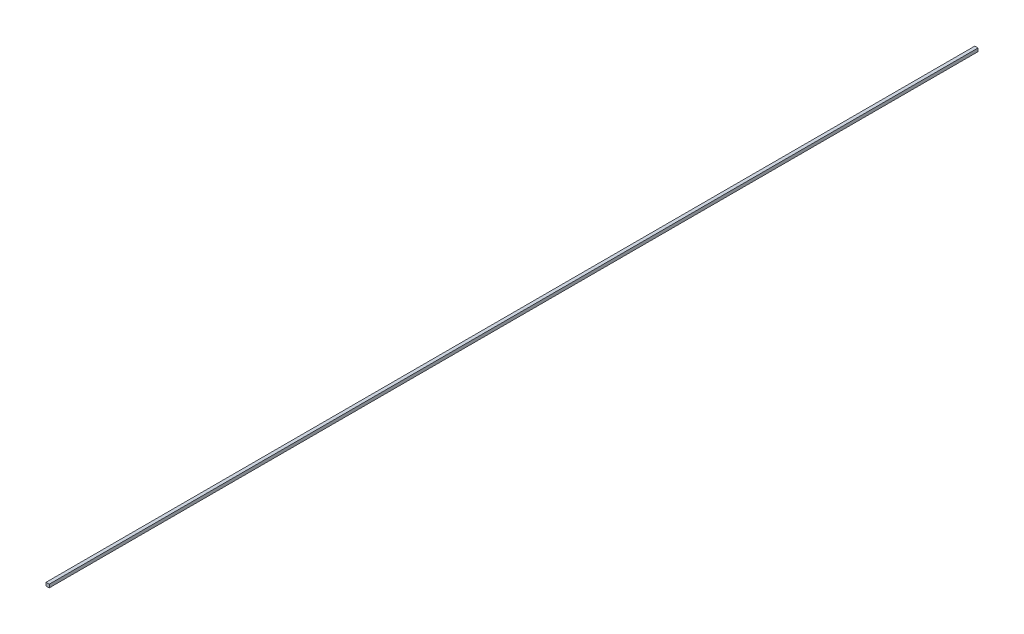
from build123d import *

# Parameters (mm, degrees)
ESBO_O1_W                = 0.35
ESBO_O1_H                = 0.35
RESSALTO_EXTRUS_O1_DEPTH = 100


with BuildPart() as part:
    # Esboço1 → Ressalto-extrusão1 (new body)
    with BuildSketch(Plane.XY):
        Rectangle(ESBO_O1_W, ESBO_O1_H)
    extrude(amount=RESSALTO_EXTRUS_O1_DEPTH)


solid = part.part
